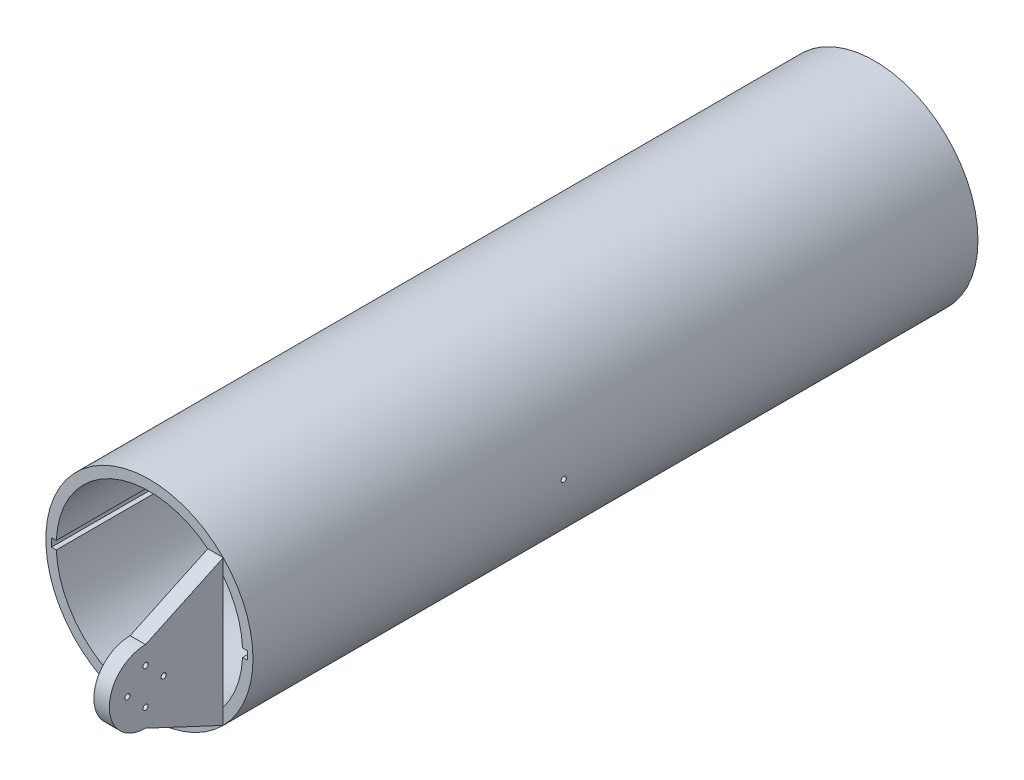
from build123d import *

# Parameters (mm, degrees)
SKETCH1_R                = 50
BOSS_EXTRUDE1_DEPTH      = 250
BOSS_EXTRUDE1_DEPTH_BACK = 100
BOSS_EXTRUDE2_DEPTH      = 55
SKETCH7_R                = 1.25
CUT_EXTRUDE4_DEPTH       = 75
CUT_EXTRUDE4_DEPTH_BACK  = 96
CUT_EXTRUDE5_DEPTH       = 96
CUT_EXTRUDE6_DEPTH       = 96
SKETCH10_R               = 1.25
CUT_EXTRUDE7_DEPTH       = 96


with BuildPart() as part:
    # Sketch1 → Boss-Extrude1 (new body, two sides)
    with BuildSketch(Plane.XY) as boss_extrude1_sk:
        Circle(SKETCH1_R)
        with BuildLine():
            Line((-44.955555556, 1.999506112), (-47.255555556, 1.999506112))
            Line((-47.255555556, 1.999506112), (-47.255555556, -1.999506112))
            Line((-47.255555556, -1.999506112), (-44.955555556, -1.999506112))
            ThreePointArc((-44.955555556, -1.999506112), (0, -45), (44.955555556, -1.999506112))
            Line((44.955555556, -1.999506112), (47.255555556, -1.999506112))
            Line((47.255555556, -1.999506112), (47.255555556, 1.999506112))
            Line((47.255555556, 1.999506112), (44.955555556, 1.999506112))
            ThreePointArc((44.955555556, 1.999506112), (0, 45), (-44.955555556, 1.999506112))
        make_face(mode=Mode.SUBTRACT)
    extrude(amount=BOSS_EXTRUDE1_DEPTH)
    extrude(boss_extrude1_sk.sketch, amount=-BOSS_EXTRUDE1_DEPTH_BACK)

    # Sketch3 → Boss-Extrude2 (add)
    with BuildSketch(Plane.XY.offset(250)):
        Polygon((28.2, 0), (28.2, 35.067934071), (35.640426485, 35.067934071), (35.640426485, -35.067934071), (28.2, -35.067934071), align=None)
    extrude(amount=BOSS_EXTRUDE2_DEPTH)

    # Sketch7 → Cut-Extrude4 (cut, two sides)
    with BuildSketch(Plane(origin=(35.640426485, 0, 0), x_dir=(0, 0, -1), z_dir=(1, 0, 0))) as cut_extrude4_sk:
        with Locations((-100, 0)):
            Circle(SKETCH7_R)
    extrude(amount=CUT_EXTRUDE4_DEPTH, mode=Mode.SUBTRACT)
    extrude(cut_extrude4_sk.sketch, amount=-CUT_EXTRUDE4_DEPTH_BACK, mode=Mode.SUBTRACT)

    # Sketch8 → Cut-Extrude5 (cut)
    with BuildSketch(Plane(origin=(35.640426485, 0, 0), x_dir=(0, 0, -1), z_dir=(1, 0, 0))):
        with BuildLine():
            Line((-287.5, 17.5), (-250, 35.067934071))
            Line((-250, 35.067934071), (-305, 35.067934071))
            Line((-305, 35.067934071), (-305, 0))
            ThreePointArc((-305, 0), (-299.874368671, 12.374368671), (-287.5, 17.5))
        make_face()
    extrude(amount=-CUT_EXTRUDE5_DEPTH, mode=Mode.SUBTRACT)

    # Sketch9 → Cut-Extrude6 (cut)
    with BuildSketch(Plane(origin=(35.640426485, 0, 0), x_dir=(0, 0, -1), z_dir=(1, 0, 0))):
        with BuildLine():
            Line((-287.5, -17.5), (-250, -35.067934071))
            Line((-250, -35.067934071), (-305, -35.067934071))
            Line((-305, -35.067934071), (-305, 0))
            ThreePointArc((-305, 0), (-299.874368671, -12.374368671), (-287.5, -17.5))
        make_face()
    extrude(amount=-CUT_EXTRUDE6_DEPTH, mode=Mode.SUBTRACT)

    # Sketch10 → Cut-Extrude7 (cut)
    with BuildSketch(Plane(origin=(35.640426485, 0, 0), x_dir=(0, 0, -1), z_dir=(1, 0, 0))):
        with Locations((-296.25, 0)):
            Circle(SKETCH10_R)
        with Locations((-287.5, 8.75)):
            Circle(SKETCH10_R)
        with Locations((-278.75, 0)):
            Circle(SKETCH10_R)
        with Locations((-287.5, -8.75)):
            Circle(SKETCH10_R)
    extrude(amount=-CUT_EXTRUDE7_DEPTH, mode=Mode.SUBTRACT)


solid = part.part
